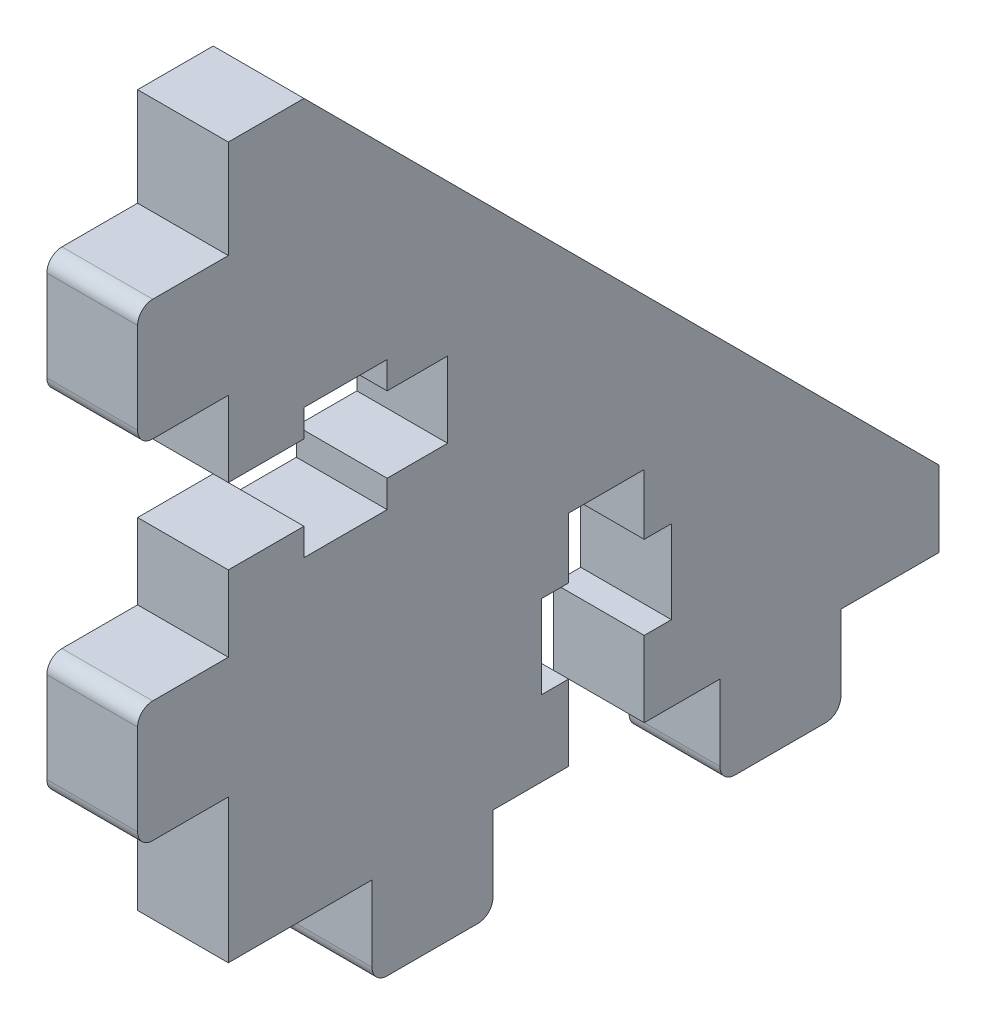
from build123d import *

# Parameters (mm, degrees)
BOSS_EXTRU_1_DEPTH      = 3
BOSS_EXTRU_2_DEPTH      = 6
ENL_V_MAT_EXTRU_1_DEPTH = 6


with BuildPart() as part:
    # Esquisse1 → Boss.-Extru.1 (new, symmetric)
    with BuildSketch(Plane(origin=(0, 0, 0), x_dir=(0, -1, 0), z_dir=(1, 0, 0))):
        Polygon((0, 0), (42, 42), (47, 42), (47, -5), (0, -5), align=None)
    extrude(amount=BOSS_EXTRU_1_DEPTH, both=True)

    # Esquisse2 → Boss.-Extru.2 (add)
    with BuildSketch(Plane(origin=(3, 0, 0), x_dir=(0, -1, 0), z_dir=(1, 0, 0))):
        with BuildLine():
            Line((47, 35.5), (47, 27.5))
            Line((47, 27.5), (52, 27.5))
            ThreePointArc((52, 27.5), (52.707106781, 27.792893219), (53, 28.5))
            Line((53, 28.5), (53, 34.5))
            ThreePointArc((53, 34.5), (52.707106781, 35.207106781), (52, 35.5))
            Line((52, 35.5), (47, 35.5))
        make_face()
        with BuildLine():
            Line((47, 12.5), (47, 4.5))
            Line((47, 4.5), (52, 4.5))
            ThreePointArc((52, 4.5), (52.707106781, 4.792893219), (53, 5.5))
            Line((53, 5.5), (53, 11.5))
            ThreePointArc((53, 11.5), (52.707106781, 12.207106781), (52, 12.5))
            Line((52, 12.5), (47, 12.5))
        make_face()
        with BuildLine():
            Line((14.5, -10), (14.5, -5))
            Line((14.5, -5), (6.5, -5))
            Line((6.5, -5), (6.5, -10))
            ThreePointArc((6.5, -10), (6.792893219, -10.707106781), (7.5, -11))
            Line((7.5, -11), (13.5, -11))
            ThreePointArc((13.5, -11), (14.207106781, -10.707106781), (14.5, -10))
        make_face()
        with BuildLine():
            Line((37.5, -10), (37.5, -5))
            Line((37.5, -5), (29.5, -5))
            Line((29.5, -5), (29.5, -10))
            ThreePointArc((29.5, -10), (29.792893219, -10.707106781), (30.5, -11))
            Line((30.5, -11), (36.5, -11))
            ThreePointArc((36.5, -11), (37.207106781, -10.707106781), (37.5, -10))
        make_face()
    extrude(amount=-BOSS_EXTRU_2_DEPTH)

    # Esquisse2_3 → Enl_v. mat.-Extru.1 (cut)
    with BuildSketch(Plane(origin=(3, 0, 0), x_dir=(0, -1, 0), z_dir=(1, 0, 0))):
        Polygon((42, 17.5), (47, 17.5), (47, 22.5), (42, 22.5), (42, 24.3), (36.5, 24.3), (36.5, 22.5), (32.5, 22.5), (32.5, 17.5), (36.5, 17.5), (36.5, 15.7), (42, 15.7), align=None)
        Polygon((19.5, -5), (24.5, -5), (24.5, 0), (26.3, 0), (26.3, 5.5), (24.5, 5.5), (24.5, 9.5), (19.5, 9.5), (19.5, 5.5), (17.7, 5.5), (17.7, 0), (19.5, 0), align=None)
    extrude(amount=-ENL_V_MAT_EXTRU_1_DEPTH, mode=Mode.SUBTRACT)


solid = part.part
